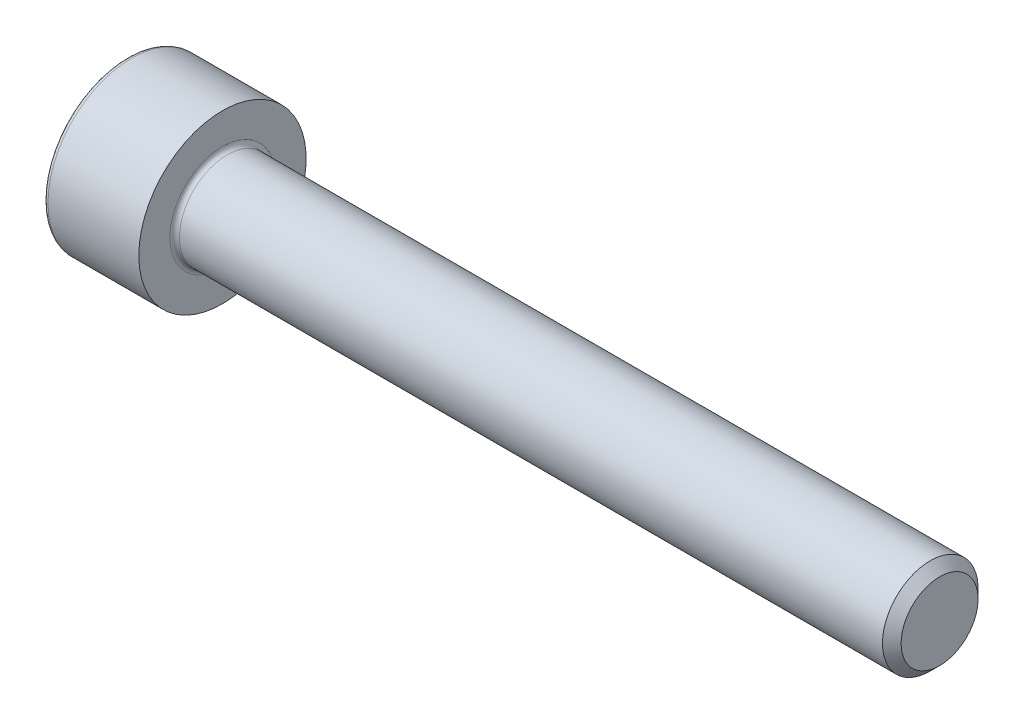
from build123d import *

# Parameters (mm, degrees)
FILLET1_R   = 0.2
FILLET2_R   = 0.2
HEX_2_DEPTH = 2


with BuildPart() as part:
    # BodySke → Base-Revolve (revolve)
    with BuildSketch(Plane.XY, mode=Mode.PRIVATE) as base_revolve_sk:
        Polygon((0, 0), (0, 3.5), (4, 3.5), (4, 2), (33.61, 2), (34, 1.61), (34, 0), align=None)
    revolve(base_revolve_sk.sketch.rotate(Axis((-31.75, 0, 0), (1, 0, 0)), 90), axis=Axis((-31.75, 0, 0), (1, 0, 0)))  # turned: the seam where the file's is

    # Fillet1
    fillet1_edges = [part.edges().sort_by_distance(p)[0] for p in [
        (4, 0, -2),
    ]]
    fillet(fillet1_edges, radius=FILLET1_R)

    # Fillet2
    fillet2_edges = [part.edges().sort_by_distance(p)[0] for p in [
        (0, 0, -3.5),
    ]]
    fillet(fillet2_edges, radius=FILLET2_R)

    # Sketch2 → Hex-PreBroach (revolve, cut)
    with BuildSketch(Plane.XY, mode=Mode.PRIVATE) as hex_prebroach_sk:
        Polygon((0, 1.5355), (2, 1.5355), (2.886521338, 0), (0, 0), align=None)
    revolve(hex_prebroach_sk.sketch.rotate(Axis((0, 0, 0), (1, 0, 0)), 90), axis=Axis((0, 0, 0), (1, 0, 0)), mode=Mode.SUBTRACT)  # turned: the seam where the file's is

    # Sketch3 → Hex 2 (cut)
    with BuildSketch(Plane(origin=(0, 0, 0), x_dir=(0, 0.5, 0.866025404), z_dir=(-1, 0, 0))):
        Polygon((0.886521338, 1.5355), (-0.886521338, 1.5355), (-1.773042677, 0), (-0.886521338, -1.5355), (0.886521338, -1.5355), (1.773042677, 0), align=None)
    extrude(amount=-HEX_2_DEPTH, mode=Mode.SUBTRACT)


solid = part.part
